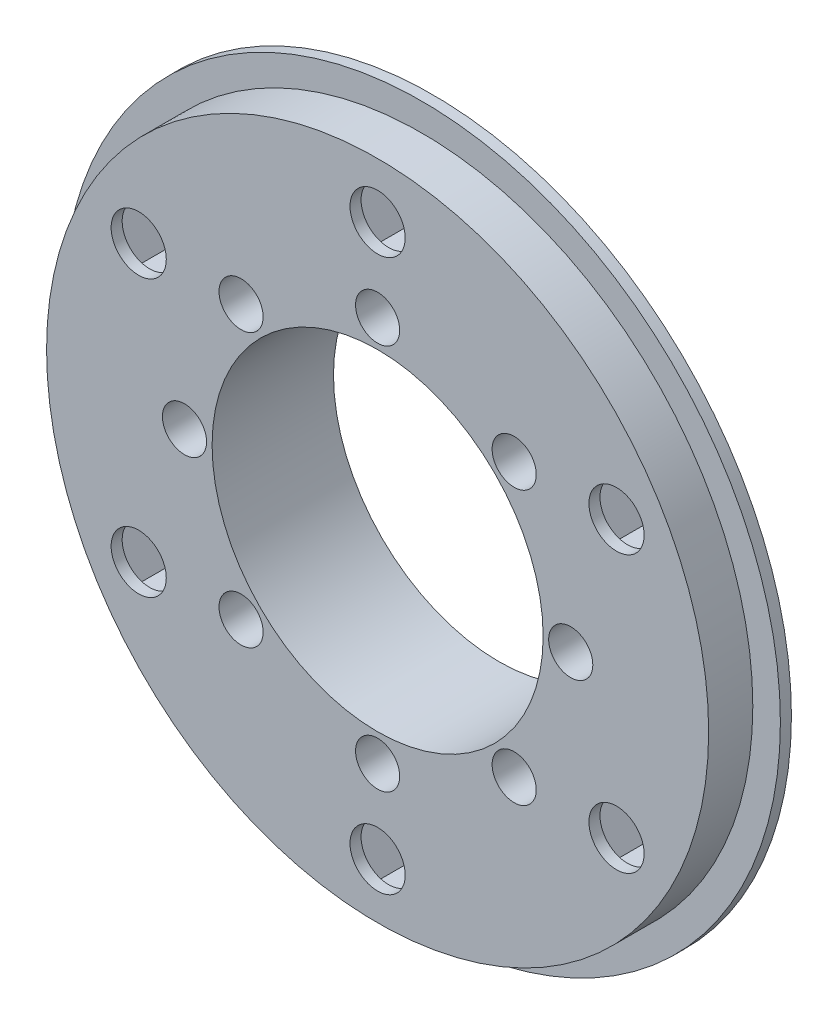
from build123d import *
from build123d.topology import SkipClean

# Parameters (mm, degrees)
SKETCH1_R               = 20
BOSS_EXTRUDE1_DEPTH     = 6
CUT_EXTRUDE1_DEPTH      = 7
CUT_EXTRUDE1_DEPTH_BACK = 29.91366459
SKETCH2_R               = 2
SKETCH3_R               = 15
CUT_EXTRUDE2_DEPTH      = 6
SKETCH4_R               = 30
SKETCH4_R_2             = 15
BOSS_EXTRUDE2_DEPTH     = 5
CUT_EXTRUDE3_START      = -7
SKETCH6_R               = 2
CUT_EXTRUDE3_DEPTH      = 7
CUT_EXTRUDE4_DEPTH      = 4
SKETCH8_R               = 2.5
CUT_EXTRUDE5_DEPTH      = 4
SKETCH9_R               = 32.5
SKETCH9_R_2             = 30
BOSS_EXTRUDE3_DEPTH     = 1


with BuildPart() as part:
    # Sketch1 → Boss-Extrude1 (new body)
    with BuildSketch(Plane.XY):
        Circle(SKETCH1_R)
    extrude(amount=BOSS_EXTRUDE1_DEPTH)

    # Sketch2 → Cut-Extrude1 (cut, two sides: drawn at the far end of the back side and taken through both)
    with BuildSketch(Plane.XY.offset(6).offset(-CUT_EXTRUDE1_DEPTH_BACK)):
        with Locations((0, 17.5)):
            Circle(SKETCH2_R)
        with Locations((12.374368671, 12.374368671)):
            Circle(SKETCH2_R)
        with Locations((17.5, 0)):
            Circle(SKETCH2_R)
        with Locations((12.374368671, -12.374368671)):
            Circle(SKETCH2_R)
        with Locations((0, -17.5)):
            Circle(SKETCH2_R)
        with Locations((-12.374368671, -12.374368671)):
            Circle(SKETCH2_R)
        with Locations((-17.5, 0)):
            Circle(SKETCH2_R)
        with Locations((-12.374368671, 12.374368671)):
            Circle(SKETCH2_R)
    extrude(amount=CUT_EXTRUDE1_DEPTH + CUT_EXTRUDE1_DEPTH_BACK, mode=Mode.SUBTRACT)

    # Sketch3 → Cut-Extrude2 (cut)
    with BuildSketch(Plane(origin=(0, 0, 0), x_dir=(-1, 0, 0), z_dir=(0, 0, -1))):
        Circle(SKETCH3_R)
    extrude(amount=-CUT_EXTRUDE2_DEPTH, mode=Mode.SUBTRACT)

    # Sketch4 → Boss-Extrude2 (add)
    with SkipClean():  # the faces are left unmerged after this step: merging them gives an invalid solid
        with BuildSketch(Plane.XY.offset(6)):
            Circle(SKETCH4_R)
            Circle(SKETCH4_R_2, mode=Mode.SUBTRACT)
        extrude(amount=BOSS_EXTRUDE2_DEPTH)
    add(part.part.scale(1), mode=Mode.REPLACE)  # the faces are merged on a copy

    # Sketch6 → Cut-Extrude3 (cut)
    with SkipClean():  # the faces are left unmerged after this step: merging them gives an invalid solid
        with BuildSketch(Plane(origin=(0, 0, 6), x_dir=(-1, 0, 0), z_dir=(0, 0, -1)).offset(CUT_EXTRUDE3_START)):
            with Locations((0, 17.5)):
                Circle(SKETCH6_R)
            with Locations((12.374368671, 12.374368671)):
                Circle(SKETCH6_R)
            with Locations((17.5, 0)):
                Circle(SKETCH6_R)
            with Locations((12.374368671, -12.374368671)):
                Circle(SKETCH6_R)
            with Locations((0, -17.5)):
                Circle(SKETCH6_R)
            with Locations((-12.374368671, -12.374368671)):
                Circle(SKETCH6_R)
            with Locations((-17.5, 0)):
                Circle(SKETCH6_R)
            with Locations((-12.374368671, 12.374368671)):
                Circle(SKETCH6_R)
        extrude(amount=CUT_EXTRUDE3_DEPTH, mode=Mode.SUBTRACT)

    # Sketch7 → Cut-Extrude4 (cut)
    with SkipClean():  # the faces are left unmerged after this step: merging them gives an invalid solid
        with BuildSketch(Plane(origin=(0, 0, 6), x_dir=(-1, 0, 0), z_dir=(0, 0, -1))):
            Polygon((23.960036171, 8.5), (26.269437248, 12.5), (23.960036171, 16.5), (19.341234018, 16.5), (17.031832941, 12.5), (19.341234018, 8.5), align=None)
            Polygon((4.618802154, 25), (2.309401077, 29), (-2.309401077, 29), (-4.618802154, 25), (-2.309401077, 21), (2.309401077, 21), align=None)
            Polygon((19.341234018, -16.5), (23.960036171, -16.5), (26.269437248, -12.5), (23.960036171, -8.5), (19.341234018, -8.5), (17.031832941, -12.5), align=None)
            Polygon((-4.618802154, -25), (-2.309401077, -29), (2.309401077, -29), (4.618802154, -25), (2.309401077, -21), (-2.309401077, -21), align=None)
            Polygon((-23.960036171, -8.5), (-26.269437248, -12.5), (-23.960036171, -16.5), (-19.341234018, -16.5), (-17.031832941, -12.5), (-19.341234018, -8.5), align=None)
            Polygon((-19.341234018, 16.5), (-23.960036171, 16.5), (-26.269437248, 12.5), (-23.960036171, 8.5), (-19.341234018, 8.5), (-17.031832941, 12.5), align=None)
        extrude(amount=-CUT_EXTRUDE4_DEPTH, mode=Mode.SUBTRACT)

    # Sketch8 → Cut-Extrude5 (cut)
    with SkipClean():  # the faces are left unmerged after this step: merging them gives an invalid solid
        with BuildSketch(Plane(origin=(0, 0, 10), x_dir=(-1, 0, 0), z_dir=(0, 0, -1))):
            with Locations((0, 25)):
                Circle(SKETCH8_R)
            with Locations((21.650635095, 12.5)):
                Circle(SKETCH8_R)
            with Locations((21.650635095, -12.5)):
                Circle(SKETCH8_R)
            with Locations((0, -25)):
                Circle(SKETCH8_R)
            with Locations((-21.650635095, -12.5)):
                Circle(SKETCH8_R)
            with Locations((-21.650635095, 12.5)):
                Circle(SKETCH8_R)
        extrude(amount=-CUT_EXTRUDE5_DEPTH, mode=Mode.SUBTRACT)

    # Sketch9 → Boss-Extrude3 (add)
    with BuildSketch(Plane(origin=(0, 0, 6), x_dir=(-1, 0, 0), z_dir=(0, 0, -1))):
        Circle(SKETCH9_R)
        Circle(SKETCH9_R_2, mode=Mode.SUBTRACT)
    extrude(amount=-BOSS_EXTRUDE3_DEPTH)


solid = part.part
